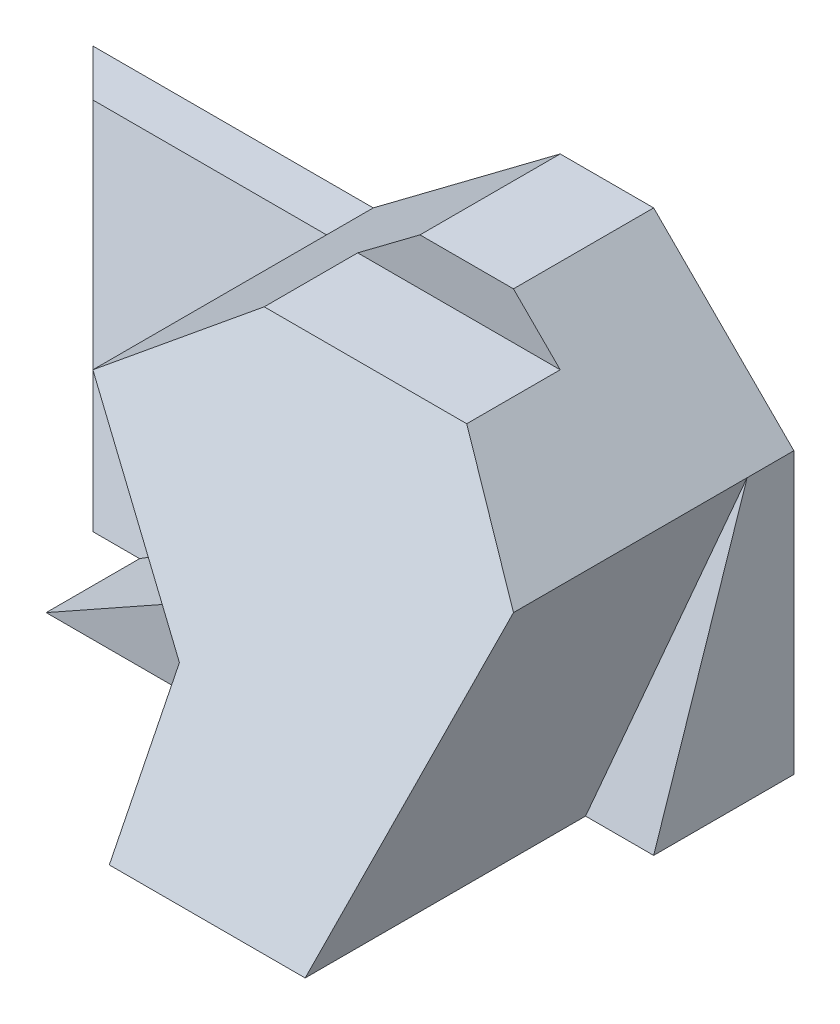
from build123d import *

# Parameters (mm, degrees)
BOSS_EXTRUDE1_DEPTH = 9
CUT_EXTRUDE1_DEPTH  = 19
CUT_EXTRUDE2_DEPTH  = 10
CUT_EXTRUDE3_DEPTH  = 10
CUT_EXTRUDE4_DEPTH  = 10
CUT_EXTRUDE6_DEPTH  = 5


with BuildPart() as part:
    # Sketch1 → Boss-Extrude1 (new body)
    with BuildSketch(Plane.XY):
        Polygon((7.5, 1.5), (4.5, 4.5), (2.5, 4.5), (-1.5, 1.5), (-7.5, 1.5), (-7.5, -4.5), (7.5, -4.5), align=None)
    extrude(amount=BOSS_EXTRUDE1_DEPTH)

    # Sketch2 → Cut-Extrude1 (cut)
    with BuildSketch(Plane.ZY.offset(7.5)):
        Polygon((3, 4.5), (3, 3.5), (5, 3.5), (9, -4.5), (9, 4.5), align=None)
    extrude(amount=-CUT_EXTRUDE1_DEPTH, mode=Mode.SUBTRACT)

    # 3DSketch1 → Cut-Extrude2 (cut, along a direction that is not the sketch's normal)
    with BuildSketch(Plane(origin=(-7.5, 1.5, 0), x_dir=(0.4082482904638631, -0.816496580927726, 0.4082482904638631), z_dir=(0.7071067811865476, 0, -0.7071067811865476))):
        Polygon((0, 0), (4.898979486, 3.464101615), (7.348469228, 0), (0.816496581, -1.154700538), align=None)
    extrude(amount=-CUT_EXTRUDE2_DEPTH, dir=(1, 0, 0), mode=Mode.SUBTRACT)

    # 3DSketch2 → Cut-Extrude3 (cut, along a direction that is not the sketch's normal)
    with BuildSketch(Plane(origin=(-6.5, 1.5, 1), x_dir=(0.9352065538199315, -0.3359312898838437, 0.11197709662794787), z_dir=(0, -0.31622776601683794, -0.9486832980505139))):
        Polygon((0, 0), (4.10995504, 5.206560243), (5.045161594, 4.852457572), (8.930397645, 0), (4.676032769, -1.770513356), align=None)
    extrude(amount=-CUT_EXTRUDE3_DEPTH, dir=(0, 0, -1), mode=Mode.SUBTRACT)


with BuildPart() as body_2:
    # of the pieces the cut leaves, the one that is kept (cut_extrude3_keep)
    add(part.part.solids().sort_by_distance((7.5, 1.5, 0))[0])

    # 3DSketch3 → Cut-Extrude4 (cut, along a direction that is not the sketch's normal)
    with BuildSketch(Plane(origin=(7.5, 1.5, 1), x_dir=(-0.22453265936457553, -0.9244601540308832, 0.3081533846769612), z_dir=(0, 0.316227766016838, 0.9486832980505139))):
        Polygon((0, 0), (6.163067694, 1.420069225), (6.490274323, 0), align=None)
    extrude(amount=CUT_EXTRUDE4_DEPTH, dir=(0, 0, 1), mode=Mode.SUBTRACT)

    # Sketch4 → Cut-Extrude6 (cut)
    with BuildSketch(Plane.XY.offset(10)):
        Polygon((1.851766406, -4.5), (1.851766406, -1.5), (-3.5, -4.5), align=None)
    extrude(amount=-CUT_EXTRUDE6_DEPTH, mode=Mode.SUBTRACT)


solid = body_2.part
